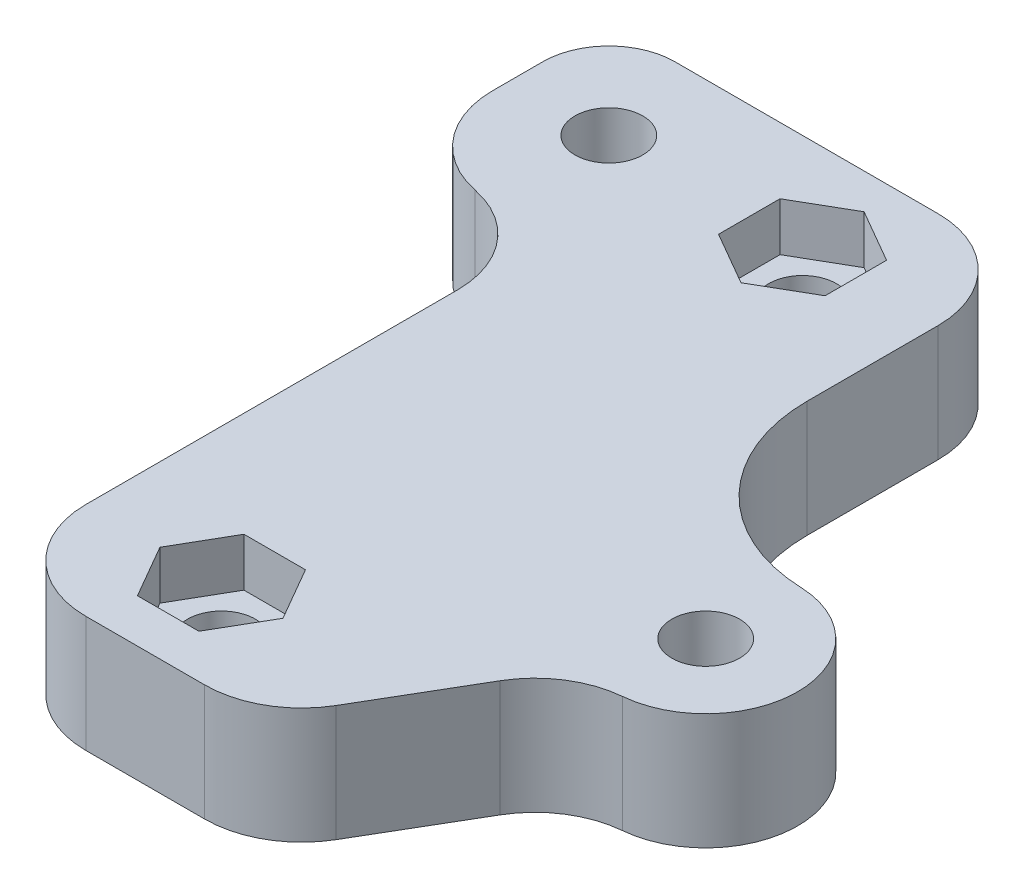
from build123d import *

# Parameters (mm, degrees)
SKETCH2_W           = 35
SKETCH2_H           = 40
SKETCH2_R           = 1.75
BOSS_EXTRUDE2_DEPTH = 6
CUT_EXTRUDE1_DEPTH  = 2.5
CUT_EXTRUDE2_DEPTH  = 2.5
CUT_EXTRUDE3_DEPTH  = 7
FILLET3_R           = 5
FILLET4_R           = 8.5


with BuildPart() as part:
    # Sketch2 → Boss-Extrude2 (new body)
    with BuildSketch(Plane(origin=(0, 0, 0), x_dir=(1, 0, 0), z_dir=(0, 1, 0))):
        with Locations((17.5, 20)):
            Rectangle(SKETCH2_W, SKETCH2_H)
        with Locations((5, 35)):
            Circle(SKETCH2_R, mode=Mode.SUBTRACT)
        with Locations((30, 15)):
            Circle(SKETCH2_R, mode=Mode.SUBTRACT)
        with Locations((15, 35)):
            Circle(SKETCH2_R, mode=Mode.SUBTRACT)
        with Locations((15, 5)):
            Circle(SKETCH2_R, mode=Mode.SUBTRACT)
    extrude(amount=BOSS_EXTRUDE2_DEPTH)

    # Sketch3 → Cut-Extrude1 (cut)
    with BuildSketch(Plane.XZ):
        Polygon((7.75, -36.58771324), (7.75, -33.41228676), (5, -31.824573519), (2.25, -33.41228676), (2.25, -36.58771324), (5, -38.175426481), align=None)
        Polygon((30, -11.824573519), (27.25, -13.41228676), (27.25, -16.58771324), (30, -18.175426481), (32.75, -16.58771324), (32.75, -13.41228676), align=None)
    extrude(amount=-CUT_EXTRUDE1_DEPTH, mode=Mode.SUBTRACT)

    # Sketch4 → Cut-Extrude2 (cut)
    with BuildSketch(Plane(origin=(0, 6, 0), x_dir=(1, 0, 0), z_dir=(0, 1, 0))):
        Polygon((17.75, 36.58771324), (15, 38.175426481), (12.25, 36.58771324), (12.25, 33.41228676), (15, 31.824573519), (17.75, 33.41228676), align=None)
        Polygon((13.41228676, 7.75), (11.824573519, 5), (13.41228676, 2.25), (16.58771324, 2.25), (18.175426481, 5), (16.58771324, 7.75), align=None)
    extrude(amount=-CUT_EXTRUDE2_DEPTH, mode=Mode.SUBTRACT)

    # Sketch5 → Cut-Extrude3 (cut, through all)
    with BuildSketch(Plane(origin=(0, 6, 0), x_dir=(1, 0, 0), z_dir=(0, 1, 0))):
        with BuildLine():
            Line((0, 36.58771324), (0, 40))
            Line((0, 40), (3.41228676, 40))
            ThreePointArc((3.41228676, 40), (0.999435653, 39.000564347), (0, 36.58771324))
        make_face()
        with BuildLine():
            Line((30, 19.75), (22, 19.75))
            Line((22, 19.75), (22, 40))
            Line((22, 40), (35, 40))
            Line((35, 40), (35, 0))
            Line((35, 0), (22, 0))
            Line((22, 0), (28, 10.25))
            Line((28, 10.25), (30, 10.25))
            ThreePointArc((30, 10.25), (34.75, 15), (30, 19.75))
        make_face()
        with BuildLine():
            Line((0, 34), (0, 0))
            Line((0, 0), (8, 0))
            Line((8, 0), (8, 29))
            Line((8, 29), (5, 29))
            ThreePointArc((5, 29), (1.464466094, 30.464466094), (0, 34))
        make_face()
    extrude(amount=-CUT_EXTRUDE3_DEPTH, mode=Mode.SUBTRACT)

    # Fillet3
    fillet3_edges = [part.edges().sort_by_distance(p)[0] for p in [
        (28, 3, -10.25),
        (22, 3, 0),
        (22, 3, -40),
        (8, 3, -29),
        (8, 3, 0),
    ]]
    fillet(fillet3_edges, radius=FILLET3_R)

    # Fillet4
    fillet4_edges = [part.edges().sort_by_distance(p)[0] for p in [
        (22, 3, -19.75),
    ]]
    fillet(fillet4_edges, radius=FILLET4_R)


solid = part.part
